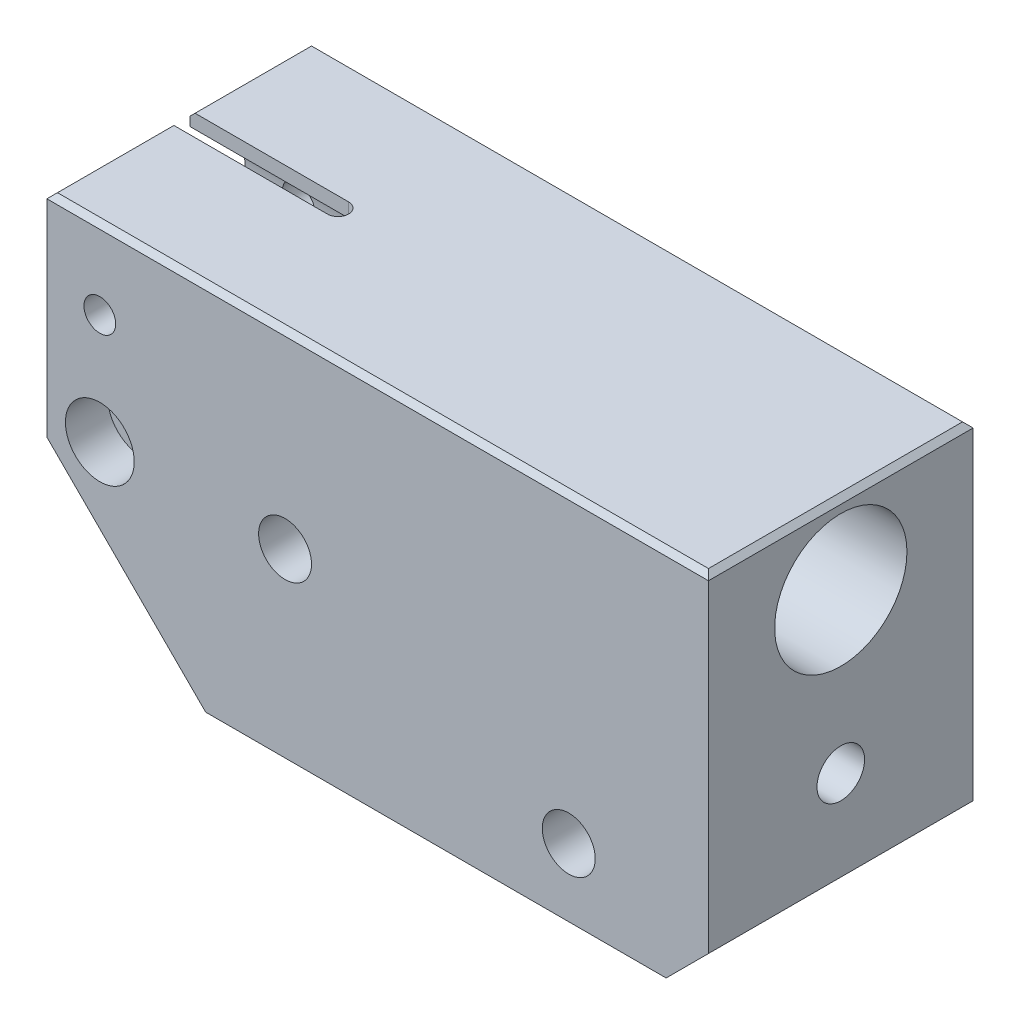
from build123d import *

# Parameters (mm, degrees)
CROQUIS1_R                     = 3
CROQUIS1_R_2                   = 4
CROQUIS1_R_3                   = 5
SALIENTE_EXTRUIR1_DEPTH        = 25
CHAFL_N1_SIZE                  = 1
CORTAR_EXTRUIR1_DEPTH          = 94.3
CROQUIS3_R                     = 4.25
CORTAR_EXTRUIR2_DEPTH          = 94.3
CROQUIS4_R                     = 6.5
CORTAR_EXTRUIR3_DEPTH          = 8
CROQUIS5_R                     = 12.5
CORTAR_EXTRUIR4_DEPTH          = 141.5
TALADRO_ROSCADO_M10X1_01_D     = 9
TALADRO_ROSCADO_M10X1_01_DEPTH = 20
TALADRO_ROSCADO_M10X1_01_TIP   = 2.703872786


with BuildPart() as part:
    # Croquis1 → Saliente-Extruir1 (new body, symmetric)
    with BuildSketch(Plane.XY):
        Polygon((0, 0), (125, 0), (125, -62), (117, -70), (30, -70), (0, -40), align=None)
        with Locations((10, -15)):
            Circle(CROQUIS1_R, mode=Mode.SUBTRACT)
        with Locations((10, -35.8)):
            Circle(CROQUIS1_R_2, mode=Mode.SUBTRACT)
        with Locations((45, -35.8)):
            Circle(CROQUIS1_R_3, mode=Mode.SUBTRACT)
        with Locations((98.6, -57.2)):
            Circle(CROQUIS1_R_3, mode=Mode.SUBTRACT)
    extrude(amount=SALIENTE_EXTRUIR1_DEPTH, both=True)

    # Chaflán1
    chafl_n1_edges = [part.edges().sort_by_distance(p)[0] for p in [
        (0, 0, 0),
        (125, 0, 0),
        (62.5, 0, 25),
        (62.5, 0, -25),
    ]]
    chamfer(chafl_n1_edges, length=CHAFL_N1_SIZE)

    # Croquis2 → Cortar-Extruir1 (cut)
    with BuildSketch(Plane(origin=(0, 0, 0), x_dir=(1, 0, 0), z_dir=(0, 1, 0))):
        with BuildLine():
            Line((30, 2), (-5.316293701, 2))
            Line((-5.316293701, 2), (-5.316293701, -2))
            Line((-5.316293701, -2), (30, -2))
            ThreePointArc((30, -2), (32, 0), (30, 2))
        make_face()
    extrude(amount=-CORTAR_EXTRUIR1_DEPTH, mode=Mode.SUBTRACT)

    # Croquis3 → Cortar-Extruir2 (cut)
    with BuildSketch(Plane(origin=(0, 0, 2), x_dir=(-1, 0, 0), z_dir=(0, 0, -1))):
        with Locations((-10, -35.8)):
            Circle(CROQUIS3_R)
    extrude(amount=-CORTAR_EXTRUIR2_DEPTH, mode=Mode.SUBTRACT)

    # Croquis4 → Cortar-Extruir3 (cut)
    with BuildSketch(Plane.XY.offset(25)):
        with Locations((10, -35.8)):
            Circle(CROQUIS4_R)
    extrude(amount=-CORTAR_EXTRUIR3_DEPTH, mode=Mode.SUBTRACT)

    # Croquis5 → Cortar-Extruir4 (cut)
    with BuildSketch(Plane(origin=(125, 0, 0), x_dir=(0, 0, -1), z_dir=(1, 0, 0))):
        with Locations((0, -15)):
            Circle(CROQUIS5_R)
    extrude(amount=-CORTAR_EXTRUIR4_DEPTH, mode=Mode.SUBTRACT)

    # Taladro roscado M10x1.01
    with Locations(Plane(origin=(125, 0, 0), x_dir=(0, 0, -1), z_dir=(1, 0, 0))):
        with Locations((0, -45)):
            Hole(TALADRO_ROSCADO_M10X1_01_D / 2, depth=TALADRO_ROSCADO_M10X1_01_DEPTH)
            with Locations((0, 0, -(TALADRO_ROSCADO_M10X1_01_DEPTH + TALADRO_ROSCADO_M10X1_01_TIP / 2))):  # 118° drill point
                Cone(0, TALADRO_ROSCADO_M10X1_01_D / 2, TALADRO_ROSCADO_M10X1_01_TIP, mode=Mode.SUBTRACT)


solid = part.part
